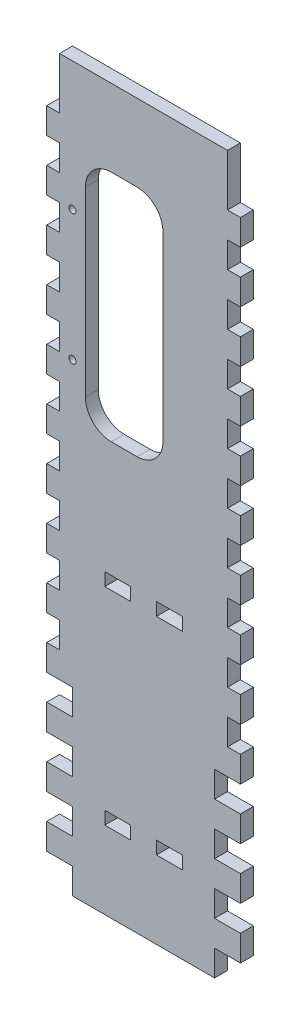
from build123d import *

# Parameters (mm, degrees)
SKETCH1_W           = 95.25
SKETCH1_H           = 355.6
BOSS_EXTRUDE1_DEPTH = 6.35
SKETCH2_W           = 12.7
SKETCH2_H           = 12.7
CUT_EXTRUDE1_DEPTH  = 7.35
LPATTERN1_COUNT     = 16
LPATTERN1_PITCH     = 25.4
SKETCH3_W           = 12.7
SKETCH3_H           = 6.35
CUT_EXTRUDE2_DEPTH  = 7.35
LPATTERN4_COUNT     = 2
LPATTERN4_PITCH     = 76.2
SKETCH5_W           = 6.35
SKETCH5_H           = 254
BOSS_EXTRUDE2_DEPTH = 6.35
SKETCH6_W           = 6.35
SKETCH6_H           = 12.7
CUT_EXTRUDE3_DEPTH  = 7.35
SKETCH7_W           = 38.1
SKETCH7_H           = 6.35
BOSS_EXTRUDE4_DEPTH = 6.35
SKETCH8_W           = 12.7
SKETCH8_H           = 6.35
CUT_EXTRUDE4_DEPTH  = 7.35
SKETCH9_R           = 1.75
CUT_EXTRUDE5_DEPTH  = 7.35
SKETCH10_W          = 38.1
SKETCH10_H          = 114.8
CUT_EXTRUDE6_DEPTH  = 7.35
FILLET1_R           = 12.7


with BuildPart() as part:
    # Sketch1 → Boss-Extrude1 (new body)
    with BuildSketch(Plane.XY):
        with Locations((47.625, 177.8)):
            Rectangle(SKETCH1_W, SKETCH1_H)
    extrude(amount=BOSS_EXTRUDE1_DEPTH)

    # Sketch2 → Cut-Extrude1 (cut, through all)
    with BuildSketch(Plane.XY.offset(6.35)):
        with Locations((6.35, 6.35)):
            Rectangle(SKETCH2_W, SKETCH2_H)
        with Locations((88.9, 6.35)):
            Rectangle(SKETCH2_W, SKETCH2_H)
    cut_extrude1 = extrude(amount=-CUT_EXTRUDE1_DEPTH, mode=Mode.SUBTRACT)

    # LPattern1: Cut-Extrude1 ×16
    with Locations(*[(0, i * LPATTERN1_PITCH, 0) for i in range(1, LPATTERN1_COUNT)]):
        add(cut_extrude1, mode=Mode.SUBTRACT)

    # Sketch3 → Cut-Extrude2 (cut, through all)
    with BuildSketch(Plane.XY.offset(6.35)):
        with Locations((34.925, 41.275)):
            Rectangle(SKETCH3_W, SKETCH3_H)
        with Locations((60.325, 41.275)):
            Rectangle(SKETCH3_W, SKETCH3_H)
    cut_extrude2 = extrude(amount=-CUT_EXTRUDE2_DEPTH, mode=Mode.SUBTRACT)

    # LPattern4: Cut-Extrude2 ×2
    with Locations(*[(0, i * LPATTERN4_PITCH, 0) for i in range(1, LPATTERN4_COUNT)]):
        add(cut_extrude2, mode=Mode.SUBTRACT)

    # Sketch5 → Boss-Extrude2 (add, through all)
    with BuildSketch(Plane.XY.offset(6.35)):
        with Locations((9.525, 228.6)):
            Rectangle(SKETCH5_W, SKETCH5_H)
        with Locations((85.725, 228.6)):
            Rectangle(SKETCH5_W, SKETCH5_H)
    extrude(amount=-BOSS_EXTRUDE2_DEPTH)

    # Sketch6 → Cut-Extrude3 (cut, through all)
    with BuildSketch(Plane.XY.offset(6.35)):
        with Locations((3.175, 349.25)):
            Rectangle(SKETCH6_W, SKETCH6_H)
        with Locations((92.075, 349.25)):
            Rectangle(SKETCH6_W, SKETCH6_H)
    extrude(amount=-CUT_EXTRUDE3_DEPTH, mode=Mode.SUBTRACT)

    # Sketch7 → Boss-Extrude4 (add, through all)
    with BuildSketch(Plane.XY.offset(6.35)):
        with Locations((47.625, 117.475)):
            Rectangle(SKETCH7_W, SKETCH7_H)
    extrude(amount=-BOSS_EXTRUDE4_DEPTH)

    # Sketch8 → Cut-Extrude4 (cut, through all)
    with BuildSketch(Plane.XY.offset(6.35)):
        with Locations((34.925, 142.875)):
            Rectangle(SKETCH8_W, SKETCH8_H)
        with Locations((60.325, 142.875)):
            Rectangle(SKETCH8_W, SKETCH8_H)
    extrude(amount=-CUT_EXTRUDE4_DEPTH, mode=Mode.SUBTRACT)

    # Sketch9 → Cut-Extrude5 (cut, through all)
    with BuildSketch(Plane.XY.offset(6.35)):
        with Locations((12.7, 292.35)):
            Circle(SKETCH9_R)
        with Locations((12.7, 228.35)):
            Circle(SKETCH9_R)
    extrude(amount=-CUT_EXTRUDE5_DEPTH, mode=Mode.SUBTRACT)

    # Sketch10 → Cut-Extrude6 (cut, through all)
    with BuildSketch(Plane.XY.offset(6.35)):
        with Locations((38.1, 260.35)):
            Rectangle(SKETCH10_W, SKETCH10_H)
    extrude(amount=-CUT_EXTRUDE6_DEPTH, mode=Mode.SUBTRACT)

    # Fillet1
    fillet1_edges = [part.edges().sort_by_distance(p)[0] for p in [
        (19.05, 202.95, 3.175),
        (19.05, 317.75, 3.175),
        (57.15, 317.75, 3.175),
        (57.15, 202.95, 3.175),
    ]]
    fillet(fillet1_edges, radius=FILLET1_R)


solid = part.part
